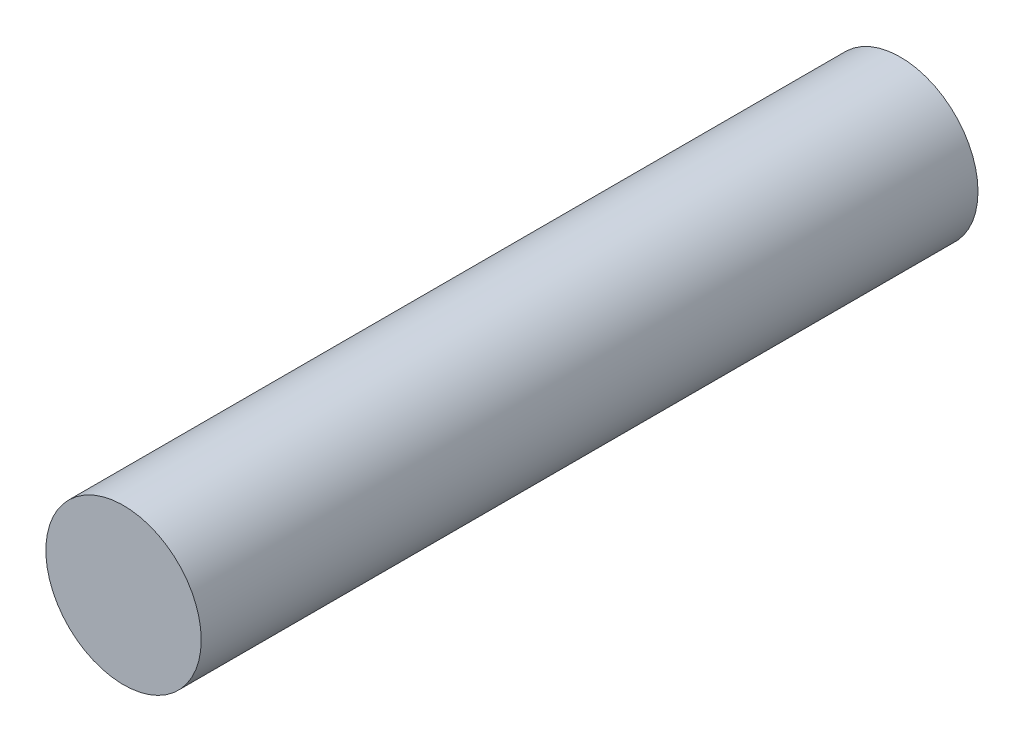
from build123d import *

# Parameters (mm, degrees)
CROQUIS1_R              = 5
SALIENTE_EXTRUIR1_DEPTH = 50


with BuildPart() as part:
    # Croquis1 → Saliente-Extruir1 (new body)
    with BuildSketch(Plane.XY):
        Circle(CROQUIS1_R)
    extrude(amount=SALIENTE_EXTRUIR1_DEPTH)


solid = part.part
